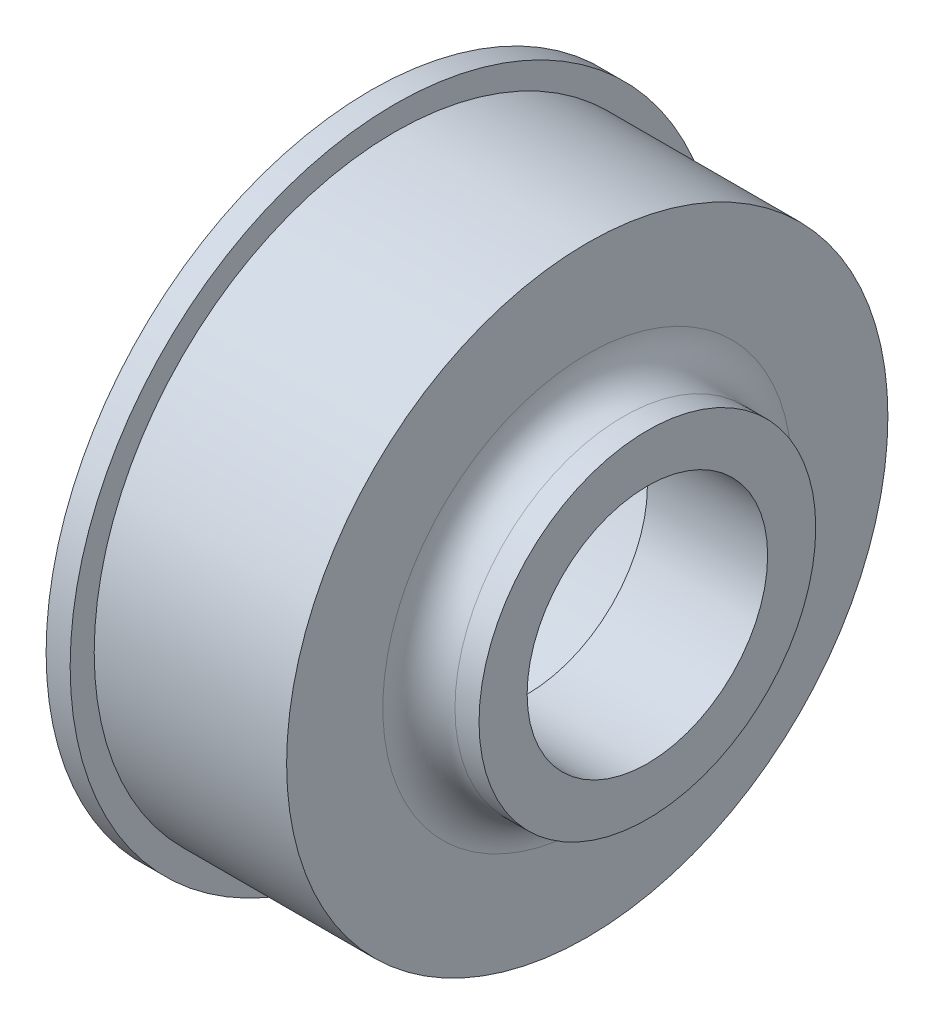
from build123d import *


with BuildPart() as part:
    # Sketch1 → Revolve1 (revolve)
    with BuildSketch(Plane.XY):
        with BuildLine():
            Line((9.207453271, 10), (9.207453271, 14))
            Line((9.207453271, 14), (7.207453271, 14))
            ThreePointArc((7.207453271, 14), (5.086132927, 14.878679656), (4.207453271, 17))
            Line((4.207453271, 17), (4.207453271, 25))
            Line((4.207453271, 25), (-11.792546729, 25))
            Line((-11.792546729, 25), (-11.792546729, 27))
            Line((-11.792546729, 27), (-13.792546729, 27))
            Line((-13.792546729, 27), (-13.792546729, 20))
            Line((-13.792546729, 20), (-0.792546729, 20))
            Line((-0.792546729, 20), (-0.792546729, 10))
            Line((-0.792546729, 10), (9.207453271, 10))
        make_face()
    revolve(axis=Axis((9.207453271, 0, 0), (-1, 0, 0)))


solid = part.part
